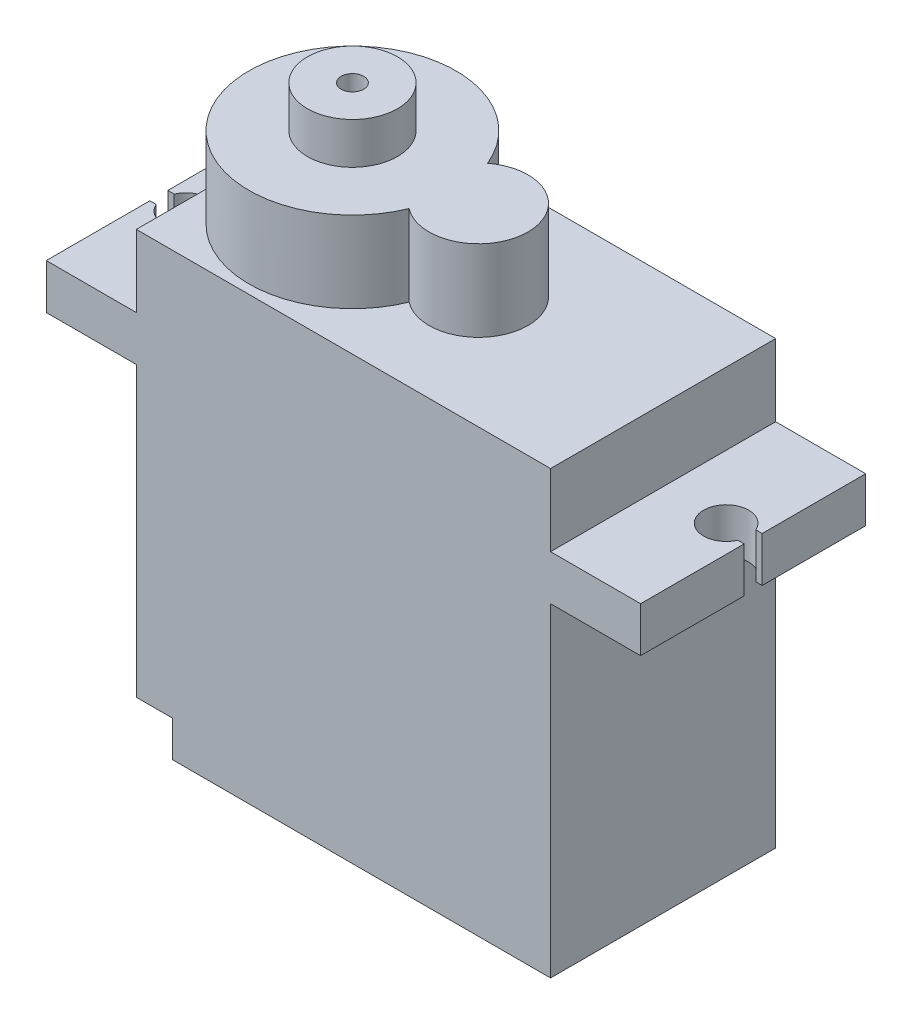
from build123d import *

# Parameters (mm, degrees)
BOSS_EXTRUDE1_DEPTH = 12.5
BOSS_EXTRUDE2_DEPTH = 4.5
CHAMFER1_SIZE       = 2
SKETCH3_W           = 2
SKETCH3_H           = 2
SKETCH3_H_2         = 3.8
CUT_EXTRUDE1_DEPTH  = 2
CUT_EXTRUDE2_DEPTH  = 5
SKETCH5_R           = 2.5
BOSS_EXTRUDE3_DEPTH = 2.3
SKETCH6_R           = 0.625
CUT_EXTRUDE3_DEPTH  = 2.3


with BuildPart() as part:
    # Sketch1 → Boss-Extrude1 (new body)
    with BuildSketch(Plane.XY):
        Polygon((11.5, 9), (11.5, -9), (-11.5, -9), (-11.5, 9), (-16.5, 9), (-16.5, 11.5), (-11.5, 11.5), (-11.5, 15.5), (11.5, 15.5), (11.5, 11.5), (16.5, 11.5), (16.5, 9), align=None)
    extrude(amount=BOSS_EXTRUDE1_DEPTH)

    # Sketch2 → Boss-Extrude2 (add)
    with BuildSketch(Plane(origin=(0, 15.5, 0), x_dir=(1, 0, 0), z_dir=(0, 1, 0))):
        with BuildLine():
            ThreePointArc((-0.428571429, -4.071721331), (-11.5, -6.25), (-0.428571429, -8.428278669))
            ThreePointArc((-0.428571429, -8.428278669), (4, -6.25), (-0.428571429, -4.071721331))
        make_face()
    extrude(amount=BOSS_EXTRUDE2_DEPTH)

    # Chamfer1
    chamfer1_edges = [part.edges().sort_by_distance(p)[0] for p in [
        (-11.5, -9, 6.25),
    ]]
    chamfer(chamfer1_edges, length=CHAMFER1_SIZE)

    # Sketch3 → Cut-Extrude1 (cut)
    with BuildSketch(Plane.XZ.offset(9)):
        with Locations((-10.5, 1)):
            Rectangle(SKETCH3_W, SKETCH3_H)
        with Locations((-10.5, 11.5)):
            Rectangle(SKETCH3_W, SKETCH3_H)
        with Locations((-10.5, 6.25)):
            Rectangle(SKETCH3_W, SKETCH3_H_2)
    extrude(amount=-CUT_EXTRUDE1_DEPTH, mode=Mode.SUBTRACT)

    # Sketch4 → Cut-Extrude2 (cut)
    with BuildSketch(Plane(origin=(0, 11.5, 0), x_dir=(1, 0, 0), z_dir=(0, 1, 0))):
        with BuildLine():
            Line((16.145643924, -6.75), (17.156032055, -6.75))
            Line((17.156032055, -6.75), (17.156032055, -5.75))
            Line((17.156032055, -5.75), (16.145643924, -5.75))
            ThreePointArc((16.145643924, -5.75), (13.75, -6.25), (16.145643924, -6.75))
        make_face()
    cut_extrude2 = extrude(amount=-CUT_EXTRUDE2_DEPTH, mode=Mode.SUBTRACT)

    # Mirror1: Cut-Extrude2 across plane
    add(cut_extrude2.mirror(Plane.ZY), mode=Mode.SUBTRACT)

    # Sketch5 → Boss-Extrude3 (add)
    with BuildSketch(Plane(origin=(0, 20, 0), x_dir=(1, 0, 0), z_dir=(0, 1, 0))):
        with Locations((-5.75, -6.25)):
            Circle(SKETCH5_R)
    extrude(amount=BOSS_EXTRUDE3_DEPTH)

    # Sketch6 → Cut-Extrude3 (cut)
    with BuildSketch(Plane(origin=(0, 22.3, 0), x_dir=(1, 0, 0), z_dir=(0, 1, 0))):
        with Locations((-5.75, -6.25)):
            Circle(SKETCH6_R)
    extrude(amount=-CUT_EXTRUDE3_DEPTH, mode=Mode.SUBTRACT)


solid = part.part
